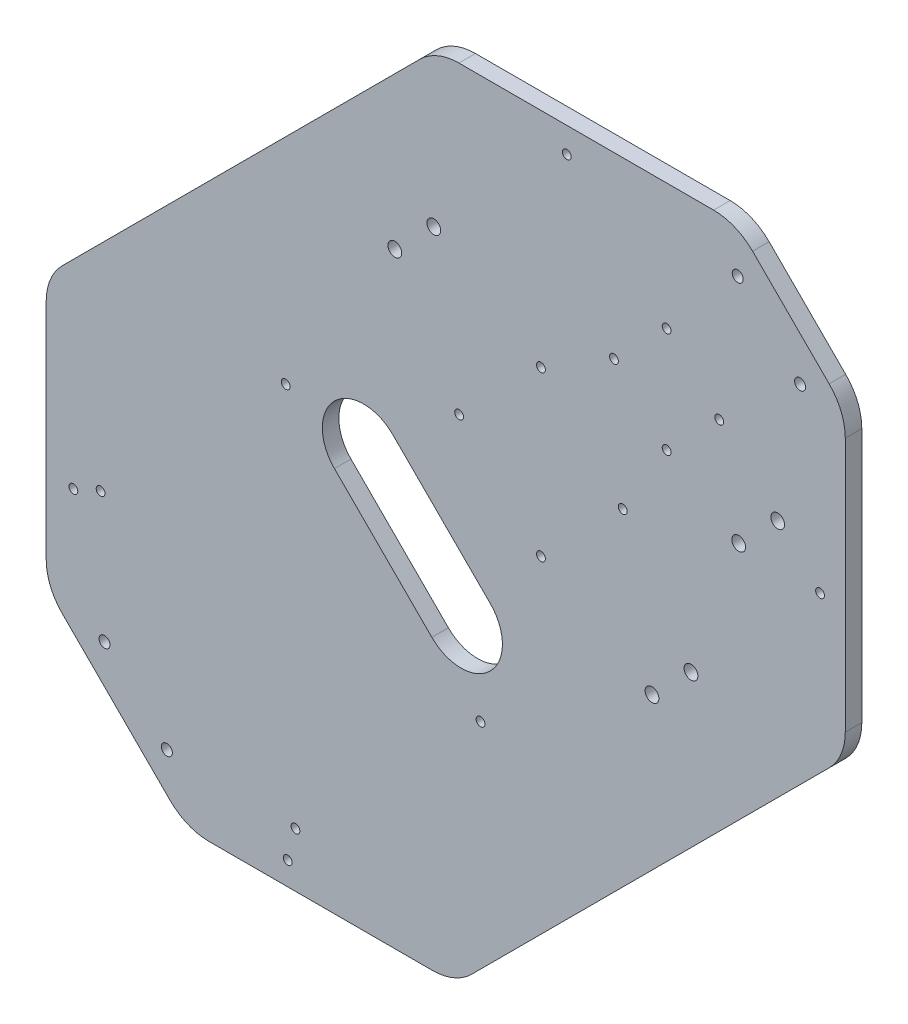
from build123d import *

# Parameters (mm, degrees)
SKETCH1_R           = 2
SKETCH1_R_2         = 1.6
SKETCH1_R_3         = 2.5
BOSS_EXTRUDE1_DEPTH = 6


with BuildPart() as part:
    # Sketch1 → Boss-Extrude1 (new body)
    with BuildSketch(Plane.XY):
        with BuildLine():
            Line((-209.57060205, 21.0430454), (-79.778754851, 150.834892598))
            ThreePointArc((-79.778754851, 150.834892598), (-73.290287875, 155.170347624), (-65.636619228, 156.692756974))
            Line((-65.636619228, 156.692756974), (26.789787643, 156.692756974))
            ThreePointArc((26.789787643, 156.692756974), (34.443456291, 155.170347624), (40.931923267, 150.834892598))
            Line((40.931923267, 150.834892598), (68.713669198, 123.053146667))
            ThreePointArc((68.713669198, 123.053146667), (73.049124224, 116.564679691), (74.571533574, 108.911011044))
            Line((74.571533574, 108.911011044), (74.571533574, 16.484604172))
            ThreePointArc((74.571533574, 16.484604172), (73.049124224, 8.830935525), (68.713669198, 2.342468549))
            Line((68.713669198, 2.342468549), (-61.078178001, -127.44937865))
            ThreePointArc((-61.078178001, -127.44937865), (-67.566644977, -131.784833676), (-75.220313624, -133.307243026))
            Line((-75.220313624, -133.307243026), (-156.333011997, -133.307243026))
            ThreePointArc((-156.333011997, -133.307243026), (-163.986680644, -131.784833676), (-170.47514762, -127.44937865))
            Line((-170.47514762, -127.44937865), (-209.57060205, -88.35392422))
            ThreePointArc((-209.57060205, -88.35392422), (-213.906057076, -81.865457244), (-215.428466426, -74.211788596))
            Line((-215.428466426, -74.211788596), (-215.428466426, 6.900909776))
            ThreePointArc((-215.428466426, 6.900909776), (-213.906057076, 14.554578423), (-209.57060205, 21.0430454))
        make_face()
        with Locations((-194.265515522, -89.516875124)):
            Circle(SKETCH1_R, mode=Mode.SUBTRACT)
        with Locations((-171.638098524, -112.144292122)):
            Circle(SKETCH1_R, mode=Mode.SUBTRACT)
        with Locations((-195.679729085, -42.847827566)):
            Circle(SKETCH1_R_2, mode=Mode.SUBTRACT)
        with Locations((-124.969050966, -113.558505684)):
            Circle(SKETCH1_R_2, mode=Mode.SUBTRACT)
        with Locations((-57.793906753, -46.383361472)):
            Circle(SKETCH1_R_2, mode=Mode.SUBTRACT)
        with Locations((-128.504584872, 24.327316647)):
            Circle(SKETCH1_R_2, mode=Mode.SUBTRACT)
        with Locations((-205.566364073, -47.103328201)):
            Circle(SKETCH1_R_2, mode=Mode.SUBTRACT)
        with Locations((-127.784618142, -124.885074131)):
            Circle(SKETCH1_R_2, mode=Mode.SUBTRACT)
        with Locations((-65.572081346, 46.247626864)):
            Circle(SKETCH1_R_2, mode=Mode.SUBTRACT)
        with Locations((-35.873596536, 16.549142054)):
            Circle(SKETCH1_R_2, mode=Mode.SUBTRACT)
        with Locations((-6.175111727, 46.247626864)):
            Circle(SKETCH1_R_2, mode=Mode.SUBTRACT)
        with Locations((-35.873596536, 75.946111674)):
            Circle(SKETCH1_R_2, mode=Mode.SUBTRACT)
        with Locations((-9.357092242, 91.85601425)):
            Circle(SKETCH1_R_2, mode=Mode.SUBTRACT)
        with Locations((9.73479085, 72.764131158)):
            Circle(SKETCH1_R_2, mode=Mode.SUBTRACT)
        with Locations((28.826673942, 91.85601425)):
            Circle(SKETCH1_R_2, mode=Mode.SUBTRACT)
        with Locations((9.73479085, 110.947897342)):
            Circle(SKETCH1_R_2, mode=Mode.SUBTRACT)
        with Locations((35.547065377, 140.295705776)):
            Circle(SKETCH1_R, mode=Mode.SUBTRACT)
        with Locations((58.174482375, 117.668288778)):
            Circle(SKETCH1_R, mode=Mode.SUBTRACT)
        with Locations((50.039877378, 70.642810815)):
            Circle(SKETCH1_R_3, mode=Mode.SUBTRACT)
        with Locations((35.897741754, 56.500675191)):
            Circle(SKETCH1_R_3, mode=Mode.SUBTRACT)
        with Locations((18.573625615, 7.356753899)):
            Circle(SKETCH1_R_3, mode=Mode.SUBTRACT)
        with Locations((4.431489991, -6.785381725)):
            Circle(SKETCH1_R_3, mode=Mode.SUBTRACT)
        with Locations((-74.764469502, 100.694849015)):
            Circle(SKETCH1_R_3, mode=Mode.SUBTRACT)
        with Locations((-88.906605125, 86.552713392)):
            Circle(SKETCH1_R_3, mode=Mode.SUBTRACT)
        with Locations((-26.494483604, 147.55062135)):
            Circle(SKETCH1_R_2, mode=Mode.SUBTRACT)
        with Locations((65.42939795, 55.626739796)):
            Circle(SKETCH1_R_2, mode=Mode.SUBTRACT)
        with BuildLine():
            Line((-89.613711907, 27.862850553), (-54.258372847, -7.492488506))
            ThreePointArc((-54.258372847, -7.492488506), (-54.258372847, -28.705691942), (-75.471576283, -28.705691942))
            Line((-75.471576283, -28.705691942), (-110.826915342, 6.649647117))
            ThreePointArc((-110.826915342, 6.649647117), (-110.826915342, 27.862850553), (-89.613711907, 27.862850553))
        make_face(mode=Mode.SUBTRACT)
    extrude(amount=BOSS_EXTRUDE1_DEPTH)


solid = part.part
